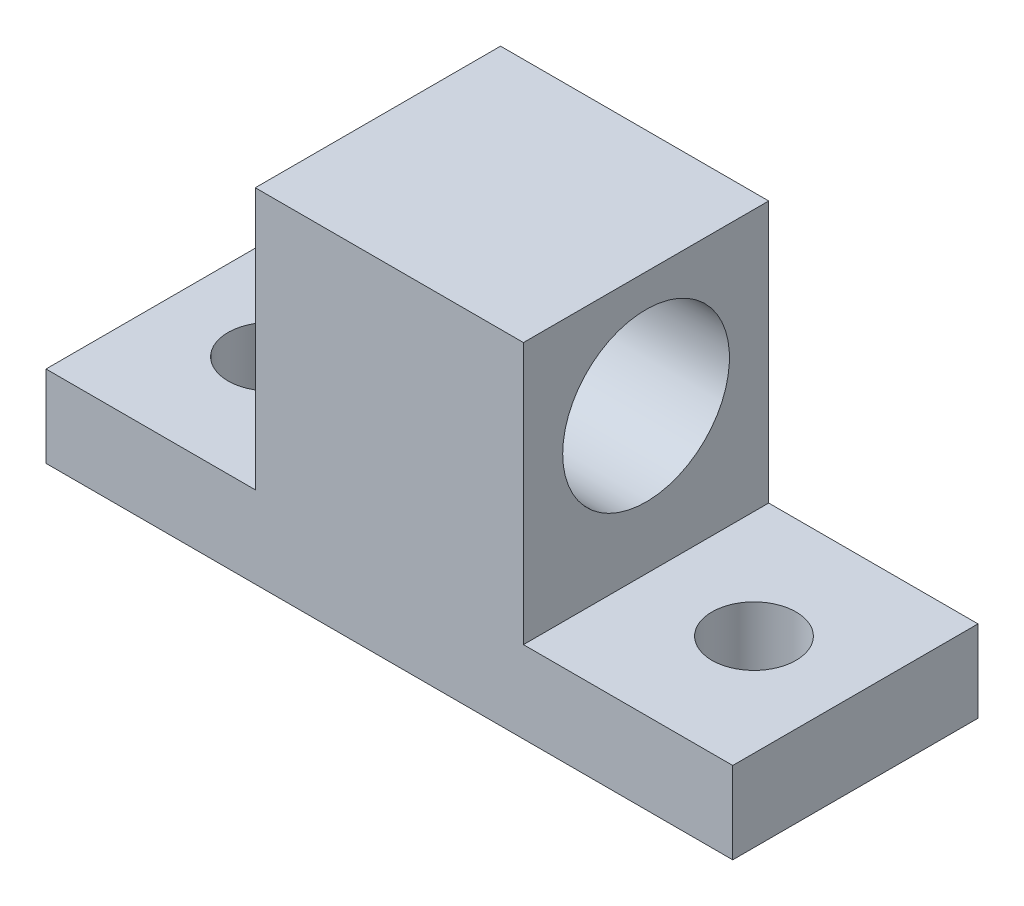
from build123d import *

# Parameters (mm, degrees)
SKETCH1_W           = 15.494
SKETCH1_H           = 19.05
SKETCH1_R           = 3.2639
SKETCH1_W_2         = 22.352
BOSS_EXTRUDE3_DEPTH = 6.35
SKETCH3_W           = 20.828
SKETCH3_H           = 19.05
BOSS_EXTRUDE4_DEPTH = 20.32
CUT_EXTRUDE1_REACH  = 39.084
SKETCH4_R           = 6.477


with BuildPart() as part:
    # Sketch1 → Boss-Extrude3 (new body)
    with BuildSketch(Plane(origin=(0, 0, 0), x_dir=(1, 0, 0), z_dir=(0, 1, 0))):
        with Locations((-27.634045528, -6.411090754)):
            Rectangle(SKETCH1_W, SKETCH1_H)
        with Locations((-27.507045528, -6.411090754)):
            Circle(SKETCH1_R, mode=Mode.SUBTRACT)
        with Locations((-8.711045528, -6.411090754)):
            Rectangle(SKETCH1_W_2, SKETCH1_H)
        with Locations((10.211954472, -6.411090754)):
            Rectangle(SKETCH1_W, SKETCH1_H)
        with Locations((10.084954472, -6.411090754)):
            Circle(SKETCH1_R, mode=Mode.SUBTRACT)
    extrude(amount=BOSS_EXTRUDE3_DEPTH)

    # Sketch3 → Boss-Extrude4 (add)
    with BuildSketch(Plane(origin=(0, 6.35, 0), x_dir=(1, 0, 0), z_dir=(0, 1, 0))):
        with Locations((-8.711045528, -6.411090754)):
            Rectangle(SKETCH3_W, SKETCH3_H)
    extrude(amount=BOSS_EXTRUDE4_DEPTH)

    # Sketch4 → Cut-Extrude1 (cut, up to next)
    with BuildSketch(Plane.ZY.offset(19.125045528), mode=Mode.PRIVATE) as cut_extrude1_sk1:
        with Locations((6.411090754, 17.656309415)):
            Circle(SKETCH4_R)
    cut_extrude1_tool1 = extrude(cut_extrude1_sk1.sketch, amount=-CUT_EXTRUDE1_REACH, mode=Mode.PRIVATE) & part.part
    add(cut_extrude1_tool1.solids().sort_by_distance((-19.125046, 17.656309, 6.411091))[0], mode=Mode.SUBTRACT)


solid = part.part
